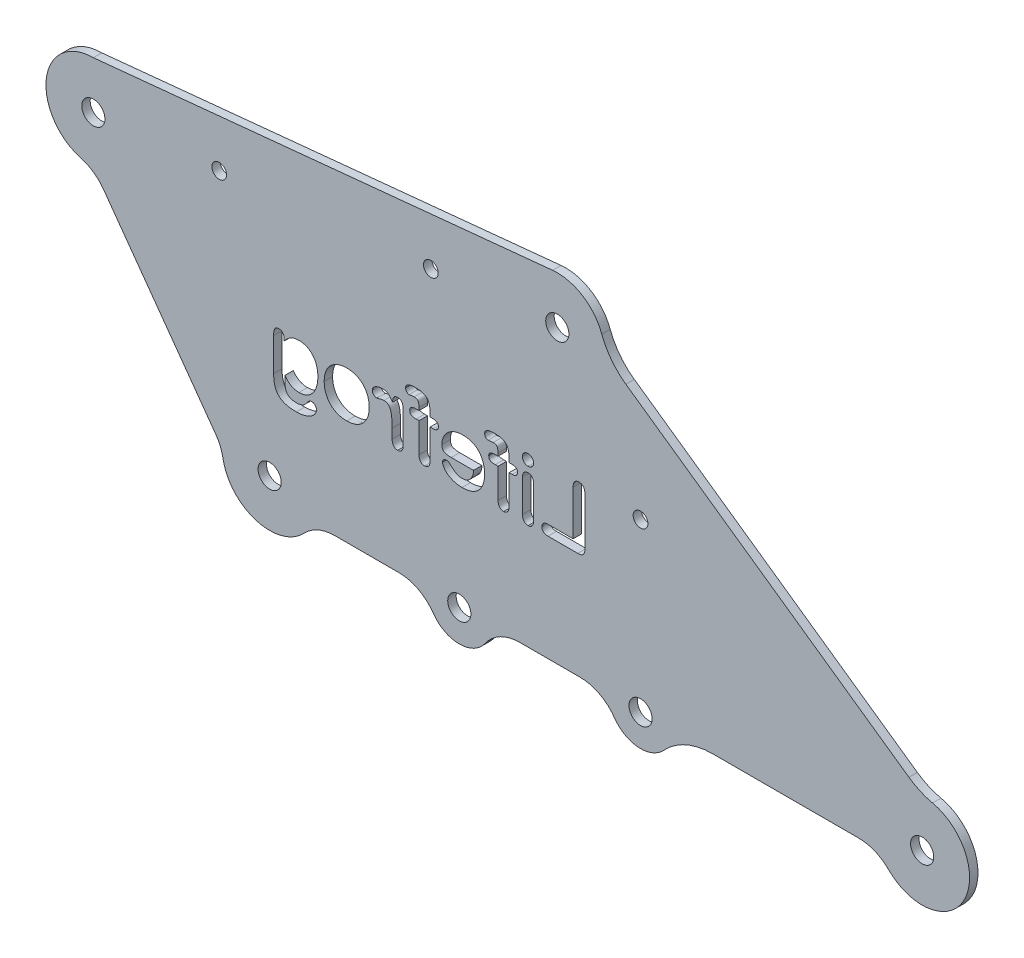
from build123d import *

# Parameters (mm, degrees)
SKETCH2_R           = 2.75
BOSS_EXTRUDE1_DEPTH = 2
SKETCH7_R           = 1.75
CUT_EXTRUDE4_DEPTH  = 3
CUT_EXTRUDE5_DEPTH  = 3
SKETCH9_R           = 4.424451358
SKETCH9_R_2         = 3.80051452
CUT_EXTRUDE6_DEPTH  = 10


with BuildPart() as part:
    # Sketch2 → Boss-Extrude1 (new body)
    with BuildSketch(Plane.XY):
        with BuildLine():
            Line((-146.482261324, -3.415116213), (-119.900209046, -40.345357838))
            ThreePointArc((-119.900209046, -40.345357838), (-118.800607084, -42.305283789), (-118.166440512, -44.46126778))
            ThreePointArc((-118.166440512, -44.46126778), (-110.313224995, -53.296457195), (-98.896144571, -50.233151699))
            ThreePointArc((-98.896144571, -50.233151699), (-95.581387, -47.909162096), (-91.616909182, -47.089734824))
            Line((-91.616909182, -47.089734824), (-76.446691, -47.089734824))
            ThreePointArc((-76.446691, -47.089734824), (-71.817590501, -48.22568222), (-68.240172934, -51.37544911))
            ThreePointArc((-68.240172934, -51.37544911), (-62.085284384, -54.589734824), (-55.930395834, -51.37544911))
            ThreePointArc((-55.930395834, -51.37544911), (-52.352978266, -48.22568222), (-47.723877768, -47.089734824))
            Line((-47.723877768, -47.089734824), (-33.446691, -47.089734824))
            ThreePointArc((-33.446691, -47.089734824), (-28.817590501, -48.22568222), (-25.240172934, -51.37544911))
            ThreePointArc((-25.240172934, -51.37544911), (-19.593639667, -54.572486651), (-13.566591065, -52.168516573))
            ThreePointArc((-13.566591065, -52.168516573), (-8.311100334, -48.415273127), (-1.990501675, -47.089734824))
            Line((-1.990501675, -47.089734824), (32.686636747, -47.089734824))
            ThreePointArc((32.686636747, -47.089734824), (36.521461692, -47.854253372), (39.769927676, -50.030911295))
            ThreePointArc((39.769927676, -50.030911295), (57.590414229, -47.521571248), (50.200722675, -31.112458317))
            ThreePointArc((50.200722675, -31.112458317), (47.278407153, -30.14859154), (44.599620096, -28.63430389))
            Line((44.599620096, -28.63430389), (-22.564700668, 18.554547573))
            ThreePointArc((-22.564700668, 18.554547573), (-25.986792869, 21.830620173), (-28.278442139, 25.976908916))
            ThreePointArc((-28.278442139, 25.976908916), (-32.864492812, 31.616465892), (-39.941717654, 33.27458296))
            Line((-39.941717654, 33.27458296), (-148.918739614, 22.469864413))
            ThreePointArc((-148.918739614, 22.469864413), (-160.065949313, 12.737169894), (-151.925623591, 0.379147243))
            ThreePointArc((-151.925623591, 0.379147243), (-148.880072017, -1.053350399), (-146.482261324, -3.415116213))
        make_face()
        with Locations((47.738629971, -42.089734824)):
            Circle(SKETCH2_R, mode=Mode.SUBTRACT)
        with Locations((-19.085284384, -47.089734824)):
            Circle(SKETCH2_R, mode=Mode.SUBTRACT)
        with Locations((-62.085284384, -47.089734824)):
            Circle(SKETCH2_R, mode=Mode.SUBTRACT)
        with Locations((-107.085284384, -42.519495684)):
            Circle(SKETCH2_R, mode=Mode.SUBTRACT)
        with Locations((-148.918739614, 11.219864413)):
            Circle(SKETCH2_R, mode=Mode.SUBTRACT)
        with Locations((-38.831758764, 22.07947281)):
            Circle(SKETCH2_R, mode=Mode.SUBTRACT)
    extrude(amount=BOSS_EXTRUDE1_DEPTH)

    # Sketch7 → Cut-Extrude4 (cut, through all)
    with BuildSketch(Plane.XY.offset(2)):
        with Locations((-119.063647537, 14.164941171)):
            Circle(SKETCH7_R)
        with Locations((-68.831758764, 19.120101507)):
            Circle(SKETCH7_R)
        with Locations((-19.085284384, -7.519495684)):
            Circle(SKETCH7_R)
    extrude(amount=-CUT_EXTRUDE4_DEPTH, mode=Mode.SUBTRACT)

    # Sketch8 → Cut-Extrude5 (cut, through all)
    with BuildSketch(Plane(origin=(0, 0, 0), x_dir=(-1, 0, 0), z_dir=(0, 0, -1))):
        with BuildLine():
            Line((35.086320726, -8.88917677), (35.086320726, -19.477067395))
            Line((35.086320726, -19.477067395), (41.039445726, -19.477067395))
            add(Edge.make_bspline(
                [(41.039445726, -19.477067395), (41.151207657, -19.479993195), (41.364330782, -19.485572515), (41.662298188, -19.554542719), (41.923339942, -19.661257744), (42.134401002, -19.819951832), (42.304522289, -20.005566477), (42.428077526, -20.217869304), (42.500347045, -20.454899643), (42.50877144, -20.620129964), (42.513078539, -20.704606457)],
                knots=[0, 0, 0, 0, 0.000334613, 0.000638087, 0.000912369, 0.001174294, 0.001423196, 0.001663395, 0.001905285, 0.002158326, 0.002158326, 0.002158326, 0.002158326], degree=3))
            add(Edge.make_bspline(
                [(42.513078539, -20.704606457), (42.508946769, -20.791061883), (42.500954328, -20.958300126), (42.427991131, -21.197153566), (42.305901504, -21.407864411), (42.137936653, -21.589554136), (41.927138947, -21.739731647), (41.667288952, -21.839448431), (41.367976859, -21.905877279), (41.153144472, -21.911559901), (41.039445726, -21.914567395)],
                knots=[0, 0, 0, 0, 0.000258876, 0.000500766, 0.000740964, 0.000983563, 0.001237974, 0.001509993, 0.00181283, 0.002153292, 0.002153292, 0.002153292, 0.002153292], degree=3))
            Line((41.039445726, -21.914567395), (33.996476976, -21.914567395))
            add(Edge.make_bspline(
                [(33.996476976, -21.914567395), (33.853353838, -21.910822677), (33.586803908, -21.903848583), (33.219164265, -21.820051925), (32.910084712, -21.691568649), (32.663815683, -21.496286799), (32.482305295, -21.2361672), (32.358100514, -20.915092293), (32.287886266, -20.530846545), (32.278723904, -20.25471837), (32.273820726, -20.106950207)],
                knots=[0, 0, 0, 0, 0.000428546, 0.000798117, 0.001124734, 0.001424881, 0.001727306, 0.002065149, 0.00245011, 0.002893278, 0.002893278, 0.002893278, 0.002893278], degree=3))
            Line((32.273820726, -20.106950207), (32.273820726, -8.88917677))
            add(Edge.make_bspline(
                [(32.273820726, -8.88917677), (32.277444522, -8.749162056), (32.284268854, -8.485486372), (32.356957437, -8.118037422), (32.476634418, -7.804802622), (32.645141816, -7.546892469), (32.856855173, -7.348035389), (33.099081612, -7.202614303), (33.373976884, -7.118889739), (33.566226734, -7.107793002), (33.665422289, -7.102067395)],
                knots=[0, 0, 0, 0, 0.0004196, 0.000790191, 0.001117701, 0.00141997, 0.001705972, 0.001981814, 0.00226075, 0.002558095, 0.002558095, 0.002558095, 0.002558095], degree=3))
            add(Edge.make_bspline(
                [(33.665422289, -7.102067395), (33.766728298, -7.106162598), (33.963485083, -7.114116312), (34.241681246, -7.204196573), (34.491196095, -7.34317393), (34.705487503, -7.541754535), (34.882515406, -7.795771782), (35.002902616, -8.111096688), (35.076257378, -8.481501141), (35.082815622, -8.747181708), (35.086320726, -8.88917677)],
                knots=[0, 0, 0, 0, 0.000302908, 0.000588308, 0.000867752, 0.001153903, 0.001457037, 0.001788351, 0.002158942, 0.002584392, 0.002584392, 0.002584392, 0.002584392], degree=3))
        make_face()
        with BuildLine():
            Line((47.086320726, -12.74464552), (47.086320726, -20.476090832))
            add(Edge.make_bspline(
                [(47.086320726, -20.476090832), (47.082420593, -20.602435528), (47.075064066, -20.84074997), (47.005182236, -21.174236118), (46.88809835, -21.460321774), (46.722706311, -21.694972614), (46.519526295, -21.876468441), (46.28964053, -22.009165841), (46.031653529, -22.087195916), (45.85149376, -22.097028675), (45.759172289, -22.102067395)],
                knots=[0, 0, 0, 0, 0.000378656, 0.00071423, 0.001016215, 0.001299911, 0.001567541, 0.00182736, 0.002090575, 0.002367225, 0.002367225, 0.002367225, 0.002367225], degree=3))
            add(Edge.make_bspline(
                [(45.759172289, -22.102067395), (45.666704772, -22.097531408), (45.487838174, -22.08875712), (45.23365211, -22.004912745), (45.006451484, -21.871389965), (44.811013414, -21.682373157), (44.650959039, -21.445866625), (44.541087672, -21.160395096), (44.473171135, -20.832780478), (44.465421067, -20.599508451), (44.461320726, -20.476090832)],
                knots=[0, 0, 0, 0, 0.00027665, 0.000535144, 0.000793904, 0.001061213, 0.001343984, 0.001643744, 0.001972979, 0.002342863, 0.002342863, 0.002342863, 0.002342863], degree=3))
            Line((44.461320726, -20.476090832), (44.461320726, -12.823747082))
            add(Edge.make_bspline(
                [(44.461320726, -12.823747082), (44.4655151, -12.699382119), (44.473445887, -12.464230884), (44.539697696, -12.136087305), (44.650415089, -11.854229206), (44.811202223, -11.625466775), (45.007817757, -11.44586487), (45.234070933, -11.317596829), (45.488859368, -11.241954113), (45.666855774, -11.232151465), (45.759172289, -11.227067395)],
                knots=[0, 0, 0, 0, 0.000372808, 0.000704911, 0.000999239, 0.00127477, 0.001536087, 0.001791911, 0.002048673, 0.002325323, 0.002325323, 0.002325323, 0.002325323], degree=3))
            add(Edge.make_bspline(
                [(45.759172289, -11.227067395), (45.851434596, -11.232364163), (46.031201162, -11.242684541), (46.289294531, -11.316791228), (46.519597684, -11.446472242), (46.719799732, -11.624386887), (46.886864263, -11.846010703), (47.003355814, -12.112795725), (47.074726656, -12.416719887), (47.082335115, -12.631916842), (47.086320726, -12.74464552)],
                knots=[0, 0, 0, 0, 0.00027665, 0.000539033, 0.000797411, 0.001063093, 0.001337313, 0.001623179, 0.001930167, 0.002267896, 0.002267896, 0.002267896, 0.002267896], degree=3))
        make_face()
        with BuildLine():
            add(Edge.make_bspline(
                [(45.788469164, -9.914567395), (45.700155278, -9.911112501), (45.527837589, -9.904371326), (45.279123369, -9.837014704), (45.05142568, -9.726888524), (44.844494731, -9.578448802), (44.672494362, -9.386651845), (44.546452039, -9.154497095), (44.472722475, -8.885778489), (44.46522284, -8.695310105), (44.461320726, -8.59620802)],
                knots=[0, 0, 0, 0, 0.000264468, 0.000516029, 0.000766308, 0.001020043, 0.001275262, 0.001532224, 0.00180588, 0.002102705, 0.002102705, 0.002102705, 0.002102705], degree=3))
            add(Edge.make_bspline(
                [(44.461320726, -8.59620802), (44.466503012, -8.504891338), (44.476546269, -8.327919822), (44.551669892, -8.073896193), (44.680826892, -7.848246813), (44.854448523, -7.652100465), (45.060826482, -7.494003153), (45.286053439, -7.371969471), (45.53257688, -7.303278473), (45.702130039, -7.29419357), (45.788469164, -7.289567395)],
                knots=[0, 0, 0, 0, 0.000273734, 0.000530495, 0.000786319, 0.001047867, 0.001310985, 0.001562597, 0.001812103, 0.002070978, 0.002070978, 0.002070978, 0.002070978], degree=3))
            add(Edge.make_bspline(
                [(45.788469164, -7.289567395), (45.871883282, -7.293289281), (46.035245133, -7.300578386), (46.272968232, -7.365176401), (46.494233713, -7.471719022), (46.696092474, -7.61868617), (46.874547315, -7.801949122), (46.996351464, -8.035133325), (47.076989401, -8.302838261), (47.083100242, -8.494958443), (47.086320726, -8.59620802)],
                knots=[0, 0, 0, 0, 0.000249866, 0.000489349, 0.000733078, 0.000982721, 0.001235592, 0.001492554, 0.001764195, 0.002066861, 0.002066861, 0.002066861, 0.002066861], degree=3))
            add(Edge.make_bspline(
                [(47.086320726, -8.59620802), (47.082548229, -8.694407685), (47.075299369, -8.883098506), (46.999769728, -9.148438196), (46.878868744, -9.381879948), (46.705206821, -9.571319036), (46.504492812, -9.722899361), (46.282136483, -9.833786351), (46.041845864, -9.904963009), (45.873933033, -9.911327839), (45.788469164, -9.914567395)],
                knots=[0, 0, 0, 0, 0.000293905, 0.000564738, 0.000820311, 0.00107553, 0.001328656, 0.001571042, 0.001817728, 0.002073434, 0.002073434, 0.002073434, 0.002073434], degree=3))
        make_face()
        with BuildLine():
            Line((49.632219164, -11.414567395), (50.273820726, -11.414567395))
            Line((50.273820726, -11.414567395), (50.273820726, -10.591325207))
            add(Edge.make_bspline(
                [(50.273820726, -10.591325207), (50.277514056, -10.388045332), (50.284509589, -10.00301306), (50.342549558, -9.457909943), (50.436641901, -8.978381027), (50.569332837, -8.557808501), (50.755633772, -8.195572563), (50.996610195, -7.887535194), (51.293777818, -7.633608774), (51.648730133, -7.431434885), (52.067068931, -7.280410479), (52.552532894, -7.174729198), (53.108091552, -7.111487828), (53.502156344, -7.105323868), (53.710344164, -7.102067395)],
                knots=[0, 0, 0, 0, 0.00060972, 0.00115487, 0.001642098, 0.002073827, 0.00247349, 0.00285738, 0.003239656, 0.003638653, 0.004076188, 0.004568733, 0.005126183, 0.005750543, 0.005750543, 0.005750543, 0.005750543], degree=3))
            add(Edge.make_bspline(
                [(53.710344164, -7.102067395), (53.895146779, -7.104261268), (54.241413904, -7.108371958), (54.723647309, -7.168286024), (55.135762658, -7.255167266), (55.473032061, -7.391161667), (55.744889456, -7.558653085), (55.937764712, -7.776533401), (56.05427242, -8.037027657), (56.067659952, -8.223910447), (56.074601976, -8.320817395)],
                knots=[0, 0, 0, 0, 0.00055399, 0.001038018, 0.001455897, 0.001813331, 0.002124554, 0.002404841, 0.002673751, 0.002963375, 0.002963375, 0.002963375, 0.002963375], degree=3))
            add(Edge.make_bspline(
                [(56.074601976, -8.320817395), (56.07205453, -8.384563693), (56.067042815, -8.509974928), (56.019565864, -8.690669099), (55.937272087, -8.855101057), (55.831089458, -9.002344218), (55.703605103, -9.125761707), (55.560931421, -9.215318606), (55.405925119, -9.272564588), (55.297752865, -9.278650351), (55.242570726, -9.281754895)],
                knots=[0, 0, 0, 0, 0.000190992, 0.000375748, 0.00055525, 0.000739844, 0.00091805, 0.001083881, 0.001242328, 0.00140733, 0.00140733, 0.00140733, 0.00140733], degree=3))
            add(Edge.make_bspline(
                [(55.242570726, -9.281754895), (55.211291096, -9.281243662), (55.139763808, -9.280074624), (55.017892004, -9.265550853), (54.867145158, -9.249871502), (54.639618335, -9.213428957), (54.363834674, -9.175272517), (54.14601204, -9.167906783), (54.047258226, -9.164567395)],
                knots=[0, 0, 0, 0, 9.3796e-05, 0.000214483, 0.000367838, 0.000548483, 0.000905689, 0.00120195, 0.00120195, 0.00120195, 0.00120195], degree=3))
            add(Edge.make_bspline(
                [(54.047258226, -9.164567395), (53.935335203, -9.168513751), (53.730509601, -9.175735811), (53.453388449, -9.253609551), (53.236438618, -9.387787922), (53.093840565, -9.587280743), (53.00705741, -9.82836939), (52.94477266, -10.108223991), (52.902635068, -10.432859402), (52.900145328, -10.66441903), (52.898820726, -10.78761427)],
                knots=[0, 0, 0, 0, 0.000335024, 0.000613112, 0.000854452, 0.001084726, 0.001333353, 0.001619039, 0.001943904, 0.00231323, 0.00231323, 0.00231323, 0.00231323], degree=3))
            Line((52.898820726, -10.78761427), (52.898820726, -11.414567395))
            Line((52.898820726, -11.414567395), (53.563859789, -11.414567395))
            add(Edge.make_bspline(
                [(53.563859789, -11.414567395), (53.684179087, -11.416649074), (53.910242779, -11.420560268), (54.225792592, -11.467875581), (54.49621768, -11.540251074), (54.718209635, -11.648680399), (54.893566863, -11.789413733), (55.016660753, -11.965226471), (55.094330745, -12.172143548), (55.10125483, -12.32106946), (55.104875414, -12.398942395)],
                knots=[0, 0, 0, 0, 0.000360649, 0.000677611, 0.000954881, 0.001197267, 0.001413707, 0.001621798, 0.001834054, 0.002066683, 0.002066683, 0.002066683, 0.002066683], degree=3))
            add(Edge.make_bspline(
                [(55.104875414, -12.398942395), (55.100784732, -12.506003658), (55.0933337, -12.701011923), (55.017531846, -12.965095468), (54.888175636, -13.171513058), (54.692271136, -13.302589493), (54.461307669, -13.37783369), (54.196374468, -13.437731598), (53.892808985, -13.470942071), (53.677213775, -13.474956644), (53.563859789, -13.477067395)],
                knots=[0, 0, 0, 0, 0.000320423, 0.000583638, 0.000816027, 0.001034677, 0.001274715, 0.00154196, 0.001848669, 0.002188714, 0.002188714, 0.002188714, 0.002188714], degree=3))
            Line((53.563859789, -13.477067395), (52.898820726, -13.477067395))
            Line((52.898820726, -13.477067395), (52.898820726, -20.49073927))
            add(Edge.make_bspline(
                [(52.898820726, -20.49073927), (52.894890647, -20.614179922), (52.887425469, -20.848655192), (52.816934516, -21.176561155), (52.703366177, -21.461585314), (52.538062875, -21.695052259), (52.335369862, -21.875428653), (52.106713482, -22.010618694), (51.846897908, -22.086940159), (51.664920121, -22.096942211), (51.571672289, -22.102067395)],
                knots=[0, 0, 0, 0, 0.000369884, 0.000702594, 0.001000746, 0.001284442, 0.001552072, 0.001809351, 0.002075373, 0.002354939, 0.002354939, 0.002354939, 0.002354939], degree=3))
            add(Edge.make_bspline(
                [(51.571672289, -22.102067395), (51.482224977, -22.09710813), (51.307699782, -22.087431855), (51.057160741, -22.007724342), (50.831657988, -21.876461922), (50.631448396, -21.694722042), (50.469647741, -21.460721404), (50.355528177, -21.176665365), (50.285268804, -20.8486244), (50.277769023, -20.614169302), (50.273820726, -20.49073927)],
                knots=[0, 0, 0, 0, 0.000267902, 0.000522718, 0.000779997, 0.001045453, 0.001327465, 0.001625617, 0.001958327, 0.002328211, 0.002328211, 0.002328211, 0.002328211], degree=3))
            Line((50.273820726, -20.49073927), (50.273820726, -13.477067395))
            Line((50.273820726, -13.477067395), (49.532609789, -13.477067395))
            add(Edge.make_bspline(
                [(49.532609789, -13.477067395), (49.437497333, -13.474545828), (49.257144996, -13.469764431), (49.004612129, -13.411306638), (48.782055088, -13.326305771), (48.598641031, -13.197615767), (48.451306666, -13.041843238), (48.352045043, -12.858126156), (48.285842232, -12.656347119), (48.279207657, -12.513757181), (48.275773851, -12.43995802)],
                knots=[0, 0, 0, 0, 0.000284723, 0.000539892, 0.000773827, 0.000994878, 0.001206343, 0.00141094, 0.001616645, 0.001837326, 0.001837326, 0.001837326, 0.001837326], degree=3))
            add(Edge.make_bspline(
                [(48.275773851, -12.43995802), (48.278931014, -12.359364997), (48.28493967, -12.205981751), (48.351465421, -11.99217143), (48.459813646, -11.809230275), (48.613188222, -11.659732473), (48.810357544, -11.547566221), (49.047458479, -11.470404208), (49.325403123, -11.419710271), (49.525517403, -11.416355939), (49.632219164, -11.414567395)],
                knots=[0, 0, 0, 0, 0.000241108, 0.000458873, 0.000663867, 0.000873109, 0.001093694, 0.001338283, 0.001618141, 0.001937813, 0.001937813, 0.001937813, 0.001937813], degree=3))
        make_face()
        with BuildLine():
            Line((63.993547289, -17.227067395), (58.711320726, -17.227067395))
            add(Edge.make_bspline(
                [(58.711320726, -17.227067395), (58.716485938, -17.373895282), (58.726607174, -17.661604604), (58.802714884, -18.07799563), (58.915860462, -18.469071713), (59.073647335, -18.829619398), (59.270554735, -19.153364248), (59.492765404, -19.442705533), (59.750507136, -19.684973297), (60.03645821, -19.88267243), (60.345770403, -20.033615445), (60.670482904, -20.148105778), (61.01253608, -20.212156224), (61.245255038, -20.222066531), (61.362687914, -20.227067395)],
                knots=[0, 0, 0, 0, 0.000440243, 0.000862657, 0.001265902, 0.001659452, 0.002039296, 0.002400313, 0.002750567, 0.003095948, 0.003439221, 0.003780175, 0.004126076, 0.004478419, 0.004478419, 0.004478419, 0.004478419], degree=3))
            add(Edge.make_bspline(
                [(61.362687914, -20.227067395), (61.517315025, -20.221290078), (61.81522082, -20.210159454), (62.248320892, -20.128402077), (62.65037596, -19.976572402), (63.029981243, -19.770423211), (63.382588562, -19.521193305), (63.667016112, -19.296133613), (63.89432751, -19.094787244), (64.085795058, -18.918875484), (64.304668367, -18.722900775), (64.455732274, -18.581855292), (64.535539476, -18.507340832)],
                knots=[0, 0, 0, 0, 0.000463817, 0.000893593, 0.001315356, 0.001747919, 0.002185944, 0.00260917, 0.00283544, 0.003096758, 0.003389213, 0.003716762, 0.003716762, 0.003716762, 0.003716762], degree=3))
            add(Edge.make_bspline(
                [(64.535539476, -18.507340832), (64.572653698, -18.48027204), (64.649909263, -18.423926662), (64.791469612, -18.369543996), (64.954050743, -18.338198915), (65.069560502, -18.333846809), (65.130266039, -18.331559582)],
                knots=[0, 0, 0, 0, 0.000137321, 0.000285842, 0.000450166, 0.000632184, 0.000632184, 0.000632184, 0.000632184], degree=3))
            add(Edge.make_bspline(
                [(65.130266039, -18.331559582), (65.197009882, -18.333900139), (65.324294385, -18.33836372), (65.504066974, -18.385198991), (65.666679189, -18.453914722), (65.804779268, -18.559309462), (65.921073021, -18.686697731), (66.001439392, -18.843467551), (66.053282091, -19.021621344), (66.057023071, -19.149522649), (66.058976976, -19.216325207)],
                knots=[0, 0, 0, 0, 0.000199757, 0.000380948, 0.000554072, 0.000725753, 0.000898008, 0.001067069, 0.001249769, 0.001449526, 0.001449526, 0.001449526, 0.001449526], degree=3))
            add(Edge.make_bspline(
                [(66.058976976, -19.216325207), (66.055140543, -19.281058441), (66.047007822, -19.418284177), (65.990684139, -19.630580971), (65.89753, -19.856403047), (65.771680317, -20.095129398), (65.612344825, -20.341196211), (65.409653802, -20.580823639), (65.174931597, -20.819411181), (64.902221637, -21.049528185), (64.595344086, -21.269822809), (64.249335099, -21.470546591), (63.864239991, -21.646257285), (63.446257949, -21.809324299), (62.992864569, -21.941257019), (62.504327356, -22.0333954), (61.984342492, -22.094193404), (61.625563625, -22.099400308), (61.441789476, -22.102067395)],
                knots=[0, 0, 0, 0, 0.000194157, 0.000411586, 0.000654768, 0.000926029, 0.001220182, 0.001532273, 0.001865807, 0.002223301, 0.002601333, 0.002997794, 0.003421152, 0.003870016, 0.004342868, 0.004835273, 0.005360039, 0.005911101, 0.005911101, 0.005911101, 0.005911101], degree=3))
            add(Edge.make_bspline(
                [(61.441789476, -22.102067395), (61.231648736, -22.097519737), (60.821964685, -22.088653761), (60.226784289, -22.021353682), (59.669210967, -21.908362258), (59.150569744, -21.745772772), (58.667513306, -21.542562166), (58.224053508, -21.288395048), (57.820679107, -20.987522623), (57.455460166, -20.64373407), (57.134442572, -20.257975864), (56.850340149, -19.841633038), (56.616330833, -19.388813691), (56.421842234, -18.905299727), (56.270116103, -18.389217889), (56.162139879, -17.840151988), (56.09676424, -17.258936562), (56.089857706, -16.86005426), (56.086320726, -16.655778332)],
                knots=[0, 0, 0, 0, 0.000630319, 0.00122885, 0.001794227, 0.002334443, 0.002856848, 0.003363404, 0.003863798, 0.004363265, 0.004864412, 0.005366578, 0.005872397, 0.006390314, 0.006927974, 0.007483573, 0.00806722, 0.008679868, 0.008679868, 0.008679868, 0.008679868], degree=3))
            add(Edge.make_bspline(
                [(56.086320726, -16.655778332), (56.089863596, -16.462226663), (56.096844531, -16.080848933), (56.163955879, -15.519624607), (56.268451373, -14.979723953), (56.413728423, -14.462108781), (56.604168314, -13.975533109), (56.829293377, -13.519340339), (57.098097208, -13.102077052), (57.402287332, -12.718106315), (57.750981266, -12.376213514), (58.140980683, -12.074737303), (58.573216423, -11.817183613), (59.045085371, -11.603132446), (59.551427203, -11.433045112), (60.089833345, -11.315293392), (60.656383848, -11.238702527), (61.044069017, -11.231007425), (61.242570726, -11.227067395)],
                knots=[0, 0, 0, 0, 0.000580441, 0.001143711, 0.001692994, 0.002229023, 0.002754034, 0.003258459, 0.00375257, 0.004240308, 0.00472508, 0.005213803, 0.005715738, 0.006230972, 0.006765533, 0.007314957, 0.007882205, 0.008477394, 0.008477394, 0.008477394, 0.008477394], degree=3))
            add(Edge.make_bspline(
                [(61.242570726, -11.227067395), (61.372538981, -11.22810589), (61.627045231, -11.23013949), (62.001408011, -11.265268194), (62.362503375, -11.313850777), (62.710727077, -11.382379075), (63.04253843, -11.478141357), (63.361054388, -11.589179566), (63.666118712, -11.720379466), (63.955121946, -11.874248291), (64.230989577, -12.038773815), (64.485024674, -12.223475089), (64.726773861, -12.411434191), (64.947774364, -12.616494045), (65.15303199, -12.831425773), (65.33677691, -13.06140635), (65.506460871, -13.299708893), (65.701149201, -13.632045496), (65.90499798, -14.058699678), (66.086744263, -14.582630241), (66.196585792, -15.115069491), (66.210329972, -15.472667779), (66.217180101, -15.65089552)],
                knots=[0, 0, 0, 0, 0.000389748, 0.000763211, 0.001126988, 0.00148264, 0.001826713, 0.002162134, 0.002494121, 0.002821735, 0.003143801, 0.003456784, 0.003763339, 0.004061909, 0.004360335, 0.004654079, 0.004944251, 0.005237176, 0.005808517, 0.006359774, 0.006897561, 0.007431922, 0.007431922, 0.007431922, 0.007431922], degree=3))
            add(Edge.make_bspline(
                [(66.217180101, -15.65089552), (66.215610952, -15.730068621), (66.212617901, -15.881086234), (66.186937014, -16.097314554), (66.140772023, -16.291180146), (66.075053252, -16.464024902), (65.995488051, -16.617172785), (65.89278487, -16.74579461), (65.773975455, -16.854326494), (65.582181996, -16.968584464), (65.300769745, -17.07492862), (64.916543956, -17.164445981), (64.474589043, -17.219117531), (64.159728488, -17.224321026), (63.993547289, -17.227067395)],
                knots=[0, 0, 0, 0, 0.000237467, 0.000452954, 0.000651914, 0.000833649, 0.001006674, 0.001167274, 0.001324933, 0.00148673, 0.001833821, 0.00222251, 0.002668381, 0.003166738, 0.003166738, 0.003166738, 0.003166738], degree=3))
        make_face()
        with BuildLine():
            Line((58.711320726, -15.727067395), (63.606828539, -15.727067395))
            add(Edge.make_bspline(
                [(63.606828539, -15.727067395), (63.597892017, -15.620388862), (63.580506578, -15.412852503), (63.525243597, -15.113999216), (63.460289426, -14.835108466), (63.374142884, -14.577543089), (63.272543011, -14.341165405), (63.154505162, -14.123236857), (63.017386306, -13.928050969), (62.863841728, -13.753386376), (62.694974951, -13.600302554), (62.514511391, -13.465060191), (62.318539721, -13.352382039), (62.109343802, -13.262997606), (61.88971522, -13.187447347), (61.65522259, -13.140138129), (61.409640164, -13.105158478), (61.240753138, -13.103110926), (61.154680101, -13.102067395)],
                knots=[0, 0, 0, 0, 0.000320958, 0.000624403, 0.000910764, 0.001179435, 0.001437945, 0.001681814, 0.001921584, 0.002151988, 0.00237803, 0.002604205, 0.002827324, 0.003054294, 0.003285906, 0.00352265, 0.003770844, 0.004028807, 0.004028807, 0.004028807, 0.004028807], degree=3))
            add(Edge.make_bspline(
                [(61.154680101, -13.102067395), (61.072577515, -13.10475237), (60.911762666, -13.110011447), (60.674960792, -13.138599654), (60.450175128, -13.191199261), (60.236485897, -13.265652746), (60.033877273, -13.359118289), (59.842432731, -13.474146939), (59.662756958, -13.609700616), (59.495375907, -13.766189336), (59.339368932, -13.941320054), (59.201880517, -14.138573533), (59.081832188, -14.355594311), (58.972348183, -14.589561112), (58.881951346, -14.845787112), (58.809840485, -15.122470817), (58.750931011, -15.417941176), (58.724734593, -15.622383021), (58.711320726, -15.727067395)],
                knots=[0, 0, 0, 0, 0.000246373, 0.000482572, 0.000714239, 0.000937531, 0.00116036, 0.001382438, 0.001606266, 0.001834293, 0.002068833, 0.002308603, 0.002553893, 0.002812121, 0.003082701, 0.003367665, 0.003669309, 0.003985851, 0.003985851, 0.003985851, 0.003985851], degree=3))
        make_face(mode=Mode.SUBTRACT)
        with BuildLine():
            Line((68.382219164, -11.414567395), (69.023820726, -11.414567395))
            Line((69.023820726, -11.414567395), (69.023820726, -10.591325207))
            add(Edge.make_bspline(
                [(69.023820726, -10.591325207), (69.027514056, -10.388045332), (69.034509589, -10.00301306), (69.092549558, -9.457909943), (69.186641901, -8.978381027), (69.319332837, -8.557808501), (69.505633772, -8.195572563), (69.746610195, -7.887535194), (70.043777818, -7.633608774), (70.398730133, -7.431434885), (70.817068931, -7.280410479), (71.302532894, -7.174729198), (71.858091552, -7.111487828), (72.252156344, -7.105323868), (72.460344164, -7.102067395)],
                knots=[0, 0, 0, 0, 0.00060972, 0.00115487, 0.001642098, 0.002073827, 0.00247349, 0.00285738, 0.003239656, 0.003638653, 0.004076188, 0.004568733, 0.005126183, 0.005750543, 0.005750543, 0.005750543, 0.005750543], degree=3))
            add(Edge.make_bspline(
                [(72.460344164, -7.102067395), (72.645146779, -7.104261268), (72.991413904, -7.108371958), (73.473647309, -7.168286024), (73.885762658, -7.255167266), (74.223032061, -7.391161667), (74.494889456, -7.558653085), (74.687764712, -7.776533401), (74.80427242, -8.037027657), (74.817659952, -8.223910447), (74.824601976, -8.320817395)],
                knots=[0, 0, 0, 0, 0.00055399, 0.001038018, 0.001455897, 0.001813331, 0.002124554, 0.002404841, 0.002673751, 0.002963375, 0.002963375, 0.002963375, 0.002963375], degree=3))
            add(Edge.make_bspline(
                [(74.824601976, -8.320817395), (74.82205453, -8.384563693), (74.817042815, -8.509974928), (74.769565864, -8.690669099), (74.687272087, -8.855101057), (74.581089458, -9.002344218), (74.453605103, -9.125761707), (74.310931421, -9.215318606), (74.155925119, -9.272564588), (74.047752865, -9.278650351), (73.992570726, -9.281754895)],
                knots=[0, 0, 0, 0, 0.000190992, 0.000375748, 0.00055525, 0.000739844, 0.00091805, 0.001083881, 0.001242328, 0.00140733, 0.00140733, 0.00140733, 0.00140733], degree=3))
            add(Edge.make_bspline(
                [(73.992570726, -9.281754895), (73.961291096, -9.281243662), (73.889763808, -9.280074624), (73.767892004, -9.265550853), (73.617145158, -9.249871502), (73.389618335, -9.213428957), (73.113834674, -9.175272517), (72.89601204, -9.167906783), (72.797258226, -9.164567395)],
                knots=[0, 0, 0, 0, 9.3796e-05, 0.000214483, 0.000367838, 0.000548483, 0.000905689, 0.00120195, 0.00120195, 0.00120195, 0.00120195], degree=3))
            add(Edge.make_bspline(
                [(72.797258226, -9.164567395), (72.685335203, -9.168513751), (72.480509601, -9.175735811), (72.203388449, -9.253609551), (71.986438618, -9.387787922), (71.843840565, -9.587280743), (71.75705741, -9.82836939), (71.69477266, -10.108223991), (71.652635068, -10.432859402), (71.650145328, -10.66441903), (71.648820726, -10.78761427)],
                knots=[0, 0, 0, 0, 0.000335024, 0.000613112, 0.000854452, 0.001084726, 0.001333353, 0.001619039, 0.001943904, 0.00231323, 0.00231323, 0.00231323, 0.00231323], degree=3))
            Line((71.648820726, -10.78761427), (71.648820726, -11.414567395))
            Line((71.648820726, -11.414567395), (72.313859789, -11.414567395))
            add(Edge.make_bspline(
                [(72.313859789, -11.414567395), (72.434179087, -11.416649074), (72.660242779, -11.420560268), (72.975792592, -11.467875581), (73.24621768, -11.540251074), (73.468209635, -11.648680399), (73.643566863, -11.789413733), (73.766660753, -11.965226471), (73.844330745, -12.172143548), (73.85125483, -12.32106946), (73.854875414, -12.398942395)],
                knots=[0, 0, 0, 0, 0.000360649, 0.000677611, 0.000954881, 0.001197267, 0.001413707, 0.001621798, 0.001834054, 0.002066683, 0.002066683, 0.002066683, 0.002066683], degree=3))
            add(Edge.make_bspline(
                [(73.854875414, -12.398942395), (73.850784732, -12.506003658), (73.8433337, -12.701011923), (73.767531846, -12.965095468), (73.638175636, -13.171513058), (73.442271136, -13.302589493), (73.211307669, -13.37783369), (72.946374468, -13.437731598), (72.642808985, -13.470942071), (72.427213775, -13.474956644), (72.313859789, -13.477067395)],
                knots=[0, 0, 0, 0, 0.000320423, 0.000583638, 0.000816027, 0.001034677, 0.001274715, 0.00154196, 0.001848669, 0.002188714, 0.002188714, 0.002188714, 0.002188714], degree=3))
            Line((72.313859789, -13.477067395), (71.648820726, -13.477067395))
            Line((71.648820726, -13.477067395), (71.648820726, -20.49073927))
            add(Edge.make_bspline(
                [(71.648820726, -20.49073927), (71.644890647, -20.614179922), (71.637425469, -20.848655192), (71.566934516, -21.176561155), (71.453366177, -21.461585314), (71.288062875, -21.695052259), (71.085369862, -21.875428653), (70.856713482, -22.010618694), (70.596897908, -22.086940159), (70.414920121, -22.096942211), (70.321672289, -22.102067395)],
                knots=[0, 0, 0, 0, 0.000369884, 0.000702594, 0.001000746, 0.001284442, 0.001552072, 0.001809351, 0.002075373, 0.002354939, 0.002354939, 0.002354939, 0.002354939], degree=3))
            add(Edge.make_bspline(
                [(70.321672289, -22.102067395), (70.232224977, -22.09710813), (70.057699782, -22.087431855), (69.807160741, -22.007724342), (69.581657988, -21.876461922), (69.381448396, -21.694722042), (69.219647741, -21.460721404), (69.105528177, -21.176665365), (69.035268804, -20.8486244), (69.027769023, -20.614169302), (69.023820726, -20.49073927)],
                knots=[0, 0, 0, 0, 0.000267902, 0.000522718, 0.000779997, 0.001045453, 0.001327465, 0.001625617, 0.001958327, 0.002328211, 0.002328211, 0.002328211, 0.002328211], degree=3))
            Line((69.023820726, -20.49073927), (69.023820726, -13.477067395))
            Line((69.023820726, -13.477067395), (68.282609789, -13.477067395))
            add(Edge.make_bspline(
                [(68.282609789, -13.477067395), (68.187497333, -13.474545828), (68.007144996, -13.469764431), (67.754612129, -13.411306638), (67.532055088, -13.326305771), (67.348641031, -13.197615767), (67.201306666, -13.041843238), (67.102045043, -12.858126156), (67.035842232, -12.656347119), (67.029207657, -12.513757181), (67.025773851, -12.43995802)],
                knots=[0, 0, 0, 0, 0.000284723, 0.000539892, 0.000773827, 0.000994878, 0.001206343, 0.00141094, 0.001616645, 0.001837326, 0.001837326, 0.001837326, 0.001837326], degree=3))
            add(Edge.make_bspline(
                [(67.025773851, -12.43995802), (67.028931014, -12.359364997), (67.03493967, -12.205981751), (67.101465421, -11.99217143), (67.209813646, -11.809230275), (67.363188222, -11.659732473), (67.560357544, -11.547566221), (67.797458479, -11.470404208), (68.075403123, -11.419710271), (68.275517403, -11.416355939), (68.382219164, -11.414567395)],
                knots=[0, 0, 0, 0, 0.000241108, 0.000458873, 0.000663867, 0.000873109, 0.001093694, 0.001338283, 0.001618141, 0.001937813, 0.001937813, 0.001937813, 0.001937813], degree=3))
        make_face()
        with BuildLine():
            Line((78.023820726, -18.21730177), (78.023820726, -20.464372082))
            add(Edge.make_bspline(
                [(78.023820726, -20.464372082), (78.019892411, -20.592663462), (78.012477123, -20.83483283), (77.942998305, -21.173173015), (77.826395379, -21.46268977), (77.660008013, -21.697626109), (77.457891862, -21.879946249), (77.226225762, -22.008518529), (76.969273636, -22.08740627), (76.789034454, -22.097099946), (76.696672289, -22.102067395)],
                knots=[0, 0, 0, 0, 0.000384504, 0.000725809, 0.001030497, 0.001314193, 0.001581823, 0.001840201, 0.002103416, 0.002380066, 0.002380066, 0.002380066, 0.002380066], degree=3))
            add(Edge.make_bspline(
                [(76.696672289, -22.102067395), (76.605316881, -22.09710505), (76.427986301, -22.087472609), (76.174585021, -22.009227395), (75.950610673, -21.875274697), (75.750230464, -21.695716107), (75.591715438, -21.458957778), (75.476710712, -21.174115576), (75.410996302, -20.840355995), (75.403041563, -20.602368539), (75.398820726, -20.476090832)],
                knots=[0, 0, 0, 0, 0.000273734, 0.000531346, 0.000786095, 0.001051551, 0.001331899, 0.00163276, 0.001967732, 0.002346388, 0.002346388, 0.002346388, 0.002346388], degree=3))
            Line((75.398820726, -20.476090832), (75.398820726, -13.028825207))
            add(Edge.make_bspline(
                [(75.398820726, -13.028825207), (75.402484719, -12.887967816), (75.409365917, -12.623429237), (75.466438734, -12.253599122), (75.562647251, -11.937580399), (75.705960969, -11.678454634), (75.886700953, -11.470839169), (76.115388002, -11.325648529), (76.384574397, -11.24325969), (76.575973652, -11.232631094), (76.676164476, -11.227067395)],
                knots=[0, 0, 0, 0, 0.000422373, 0.000793242, 0.001119373, 0.001407914, 0.001675543, 0.001936417, 0.002209759, 0.00251002, 0.00251002, 0.00251002, 0.00251002], degree=3))
            add(Edge.make_bspline(
                [(76.676164476, -11.227067395), (76.778250892, -11.23166171), (76.970074096, -11.240294554), (77.23647969, -11.31618665), (77.457457209, -11.448839438), (77.627712083, -11.63900255), (77.758010721, -11.876050227), (77.852605586, -12.159893812), (77.912208923, -12.492418163), (77.927694018, -12.729745798), (77.935930101, -12.855973645)],
                knots=[0, 0, 0, 0, 0.000305826, 0.000574656, 0.000821863, 0.001068601, 0.001330968, 0.001628371, 0.001962214, 0.002341515, 0.002341515, 0.002341515, 0.002341515], degree=3))
            add(Edge.make_bspline(
                [(77.935930101, -12.855973645), (78.015060213, -12.728702257), (78.166410553, -12.485273209), (78.414258837, -12.155879517), (78.661252631, -11.872664951), (78.918064986, -11.635812705), (79.199992654, -11.445181426), (79.525823034, -11.317799074), (79.892305657, -11.240889927), (80.150364302, -11.231818927), (80.285539476, -11.227067395)],
                knots=[0, 0, 0, 0, 0.000449399, 0.000859555, 0.001235207, 0.001575354, 0.001905253, 0.002249625, 0.002617939, 0.003023095, 0.003023095, 0.003023095, 0.003023095], degree=3))
            add(Edge.make_bspline(
                [(80.285539476, -11.227067395), (80.426467245, -11.232489358), (80.70936151, -11.243373249), (81.129162593, -11.320929872), (81.541294315, -11.453132582), (81.873448057, -11.600397905), (82.12154417, -11.742608322), (82.286513298, -11.857020394), (82.423463313, -11.98382965), (82.540429583, -12.115426572), (82.630091374, -12.257833616), (82.691453181, -12.409798496), (82.732078243, -12.569674136), (82.735800435, -12.679941298), (82.737687914, -12.735856457)],
                knots=[0, 0, 0, 0, 0.000422698, 0.000848512, 0.001275654, 0.00171888, 0.001935459, 0.00213299, 0.002319618, 0.002494076, 0.002659908, 0.002821493, 0.002984216, 0.003151619, 0.003151619, 0.003151619, 0.003151619], degree=3))
            add(Edge.make_bspline(
                [(82.737687914, -12.735856457), (82.734447601, -12.813574254), (82.728170407, -12.9641306), (82.658798765, -13.177988977), (82.553564502, -13.372817877), (82.402963372, -13.536083886), (82.232143043, -13.670264449), (82.04869511, -13.768279515), (81.85786951, -13.830801857), (81.727395914, -13.839133704), (81.662492601, -13.843278332)],
                knots=[0, 0, 0, 0, 0.000232352, 0.000450117, 0.000667803, 0.000891881, 0.00111106, 0.001316827, 0.001513269, 0.001707713, 0.001707713, 0.001707713, 0.001707713], degree=3))
            add(Edge.make_bspline(
                [(81.662492601, -13.843278332), (81.629178627, -13.840040056), (81.542984296, -13.831661558), (81.39025665, -13.792022204), (81.183740219, -13.737267753), (80.939095726, -13.659990651), (80.677274642, -13.576472525), (80.415801332, -13.523477689), (80.172440405, -13.484406004), (80.015169718, -13.479444147), (79.939836351, -13.477067395)],
                knots=[0, 0, 0, 0, 0.000100296, 0.0002595, 0.000471998, 0.000741673, 0.001029021, 0.001295639, 0.001541331, 0.001767221, 0.001767221, 0.001767221, 0.001767221], degree=3))
            add(Edge.make_bspline(
                [(79.939836351, -13.477067395), (79.845889074, -13.48141761), (79.66407233, -13.489836608), (79.402436427, -13.542788927), (79.170931902, -13.646030446), (78.963806071, -13.78176069), (78.785197235, -13.961357491), (78.627437355, -14.175620461), (78.492532222, -14.42885195), (78.379665037, -14.716376161), (78.288170049, -15.037011302), (78.209419115, -15.386257938), (78.144574547, -15.764579045), (78.099652318, -16.17561647), (78.064172897, -16.623081436), (78.042345893, -17.113612554), (78.02739976, -17.649826852), (78.025046467, -18.022954037), (78.023820726, -18.21730177)],
                knots=[0, 0, 0, 0, 0.000281997, 0.00054575, 0.000795032, 0.001037984, 0.001284513, 0.001550535, 0.001833686, 0.002142695, 0.002475508, 0.002833002, 0.003216388, 0.003626303, 0.004073002, 0.00456282, 0.005099153, 0.005682191, 0.005682191, 0.005682191, 0.005682191], degree=3))
        make_face()
        with BuildLine():
            add(Edge.make_bspline(
                [(94.148820726, -16.67042677), (94.144486428, -16.865958198), (94.135962174, -17.250509443), (94.063694953, -17.815248603), (93.947256433, -18.356735194), (93.783210596, -18.872727585), (93.575555832, -19.359535852), (93.326640268, -19.813005753), (93.033540056, -20.230278447), (92.700172687, -20.609939276), (92.32896808, -20.9531364), (91.919659255, -21.251299839), (91.478131715, -21.51184656), (91.000994931, -21.724708392), (90.492501837, -21.896725611), (89.950942693, -22.014013606), (89.380489134, -22.090278252), (88.989896722, -22.098082029), (88.790422289, -22.102067395)],
                knots=[0, 0, 0, 0, 0.000586406, 0.001153284, 0.001704937, 0.002246033, 0.002774978, 0.003290312, 0.003795052, 0.004301608, 0.004803364, 0.005308469, 0.005817966, 0.006338536, 0.006873097, 0.00742538, 0.007998439, 0.008596555, 0.008596555, 0.008596555, 0.008596555], degree=3))
            add(Edge.make_bspline(
                [(88.790422289, -22.102067395), (88.591870928, -22.098480665), (88.203960118, -22.091473252), (87.638922615, -22.010038917), (87.101578123, -21.894122427), (86.597818959, -21.719498742), (86.124926323, -21.501305834), (85.684600318, -21.240748892), (85.277774178, -20.936460383), (84.904876516, -20.593622978), (84.569894039, -20.211571465), (84.277056806, -19.794745386), (84.02509942, -19.345794671), (83.821438064, -18.863747925), (83.658781072, -18.352053245), (83.547410974, -17.811904116), (83.473790099, -17.246665517), (83.465530656, -16.861096277), (83.461320726, -16.664567395)],
                knots=[0, 0, 0, 0, 0.000595188, 0.001162822, 0.001709388, 0.002242116, 0.002758572, 0.003269557, 0.003774051, 0.004279946, 0.004786502, 0.005295324, 0.005805536, 0.006327941, 0.006862567, 0.007413605, 0.007980483, 0.008569816, 0.008569816, 0.008569816, 0.008569816], degree=3))
            add(Edge.make_bspline(
                [(83.461320726, -16.664567395), (83.465514225, -16.466082785), (83.473742721, -16.076615619), (83.547624747, -15.505610155), (83.658102464, -14.959085186), (83.824393346, -14.441866346), (84.031384338, -13.954809255), (84.28098393, -13.502415749), (84.569020413, -13.085777538), (84.899270526, -12.708353762), (85.269523718, -12.371342104), (85.67658854, -12.072840001), (86.121373859, -11.818014706), (86.60023799, -11.604092229), (87.110125782, -11.43336561), (87.648459537, -11.31556227), (88.211067148, -11.238923762), (88.594851206, -11.231069711), (88.790422289, -11.227067395)],
                knots=[0, 0, 0, 0, 0.000595188, 0.00116788, 0.001724652, 0.002265749, 0.002794693, 0.003310027, 0.003813089, 0.004311377, 0.004811153, 0.005312164, 0.00582272, 0.006345963, 0.006883303, 0.007432727, 0.00799707, 0.008583476, 0.008583476, 0.008583476, 0.008583476], degree=3))
            add(Edge.make_bspline(
                [(88.790422289, -11.227067395), (88.988898872, -11.231174927), (89.378472694, -11.239237275), (89.948439143, -11.31420497), (90.490442677, -11.436140384), (91.001366108, -11.60975716), (91.480472692, -11.827861391), (91.928322675, -12.083355331), (92.33525077, -12.389972109), (92.707032955, -12.732556775), (93.044393285, -13.110969179), (93.333369182, -13.530134072), (93.585085083, -13.980402785), (93.789040515, -14.465390299), (93.949727682, -14.979606196), (94.06772993, -15.519473979), (94.135154052, -16.08667861), (94.144198204, -16.472983807), (94.148820726, -16.67042677)],
                knots=[0, 0, 0, 0, 0.000595188, 0.001168247, 0.001721175, 0.002259449, 0.002783896, 0.003298454, 0.003802948, 0.004308843, 0.0048132, 0.005320341, 0.005833112, 0.006358213, 0.006895633, 0.007447286, 0.008013807, 0.008606068, 0.008606068, 0.008606068, 0.008606068], degree=3))
        make_face()
        with BuildLine():
            add(Edge.make_bspline(
                [(91.523820726, -16.67042677), (91.52166415, -16.540471396), (91.517472317, -16.287871443), (91.48242374, -15.920543914), (91.422249062, -15.575532262), (91.347241139, -15.250399141), (91.238347477, -14.950063385), (91.115116448, -14.668872274), (90.959772356, -14.413974861), (90.788871248, -14.178150822), (90.594058889, -13.971012519), (90.386177552, -13.786309146), (90.158198426, -13.634549), (89.916762502, -13.505920097), (89.656972659, -13.41067581), (89.382530068, -13.338976081), (89.091429338, -13.298458846), (88.892104067, -13.292570974), (88.790422289, -13.289567395)],
                knots=[0, 0, 0, 0, 0.000389825, 0.000757719, 0.001105465, 0.001440142, 0.001757036, 0.00206254, 0.00235948, 0.002650701, 0.002934699, 0.003210852, 0.003483061, 0.003754322, 0.004029666, 0.004311054, 0.004603978, 0.004909018, 0.004909018, 0.004909018, 0.004909018], degree=3))
            add(Edge.make_bspline(
                [(88.790422289, -13.289567395), (88.659103624, -13.293167537), (88.402886757, -13.300191802), (88.031896286, -13.381687907), (87.682368849, -13.501977975), (87.361299048, -13.680841795), (87.069660153, -13.904384313), (86.809174008, -14.175320472), (86.591638168, -14.498289914), (86.405589523, -14.862686984), (86.265324847, -15.26874037), (86.158586264, -15.706832305), (86.097485862, -16.178473495), (86.090114639, -16.503261048), (86.086320726, -16.67042677)],
                knots=[0, 0, 0, 0, 0.000393277, 0.000767326, 0.001134275, 0.001498794, 0.001864442, 0.00223328, 0.002620908, 0.003028387, 0.003457414, 0.003906498, 0.004379268, 0.004880664, 0.004880664, 0.004880664, 0.004880664], degree=3))
            add(Edge.make_bspline(
                [(86.086320726, -16.67042677), (86.089975868, -16.835677251), (86.09707534, -17.156647376), (86.160125836, -17.622697678), (86.260583866, -18.057364566), (86.404461982, -18.457425943), (86.584101967, -18.819204405), (86.804143131, -19.136915148), (87.056381643, -19.412930615), (87.347066752, -19.640114593), (87.667609463, -19.820805111), (88.018399206, -19.946385134), (88.395336031, -20.025112761), (88.656230869, -20.034657865), (88.790422289, -20.039567395)],
                knots=[0, 0, 0, 0, 0.000495542, 0.000962503, 0.001408056, 0.001831566, 0.002235109, 0.002616249, 0.00298735, 0.003352481, 0.003718422, 0.004086363, 0.004466151, 0.004868383, 0.004868383, 0.004868383, 0.004868383], degree=3))
            add(Edge.make_bspline(
                [(88.790422289, -20.039567395), (88.892104988, -20.036565161), (89.091432064, -20.030679926), (89.382519836, -19.990143766), (89.657009064, -19.918512142), (89.916630477, -19.823021901), (90.159172029, -19.695037632), (90.385237239, -19.539497593), (90.594238165, -19.355423123), (90.788693162, -19.147917518), (90.960812629, -18.911868837), (91.113426664, -18.65546104), (91.239281777, -18.375603349), (91.346578942, -18.076574149), (91.422386771, -17.753673501), (91.482396805, -17.41152253), (91.517390152, -17.048105533), (91.521641272, -16.798429867), (91.523820726, -16.67042677)],
                knots=[0, 0, 0, 0, 0.000305039, 0.000597964, 0.000879352, 0.001154695, 0.001425957, 0.001699816, 0.001975969, 0.002259967, 0.002551188, 0.002850647, 0.003153484, 0.003470378, 0.00380221, 0.004147067, 0.004512046, 0.004896014, 0.004896014, 0.004896014, 0.004896014], degree=3))
        make_face(mode=Mode.SUBTRACT)
        with BuildLine():
            Line((106.148820726, -13.24855177), (106.148820726, -21.073747082))
            add(Edge.make_bspline(
                [(106.148820726, -21.073747082), (106.145578638, -21.289668532), (106.139304115, -21.707548589), (106.087647215, -22.310838809), (105.997312618, -22.867172203), (105.87222542, -23.377416774), (105.710318638, -23.84506679), (105.498897586, -24.267423187), (105.251306447, -24.653258133), (104.95074422, -24.991966607), (104.608489437, -25.293090564), (104.21162859, -25.544239225), (103.771825619, -25.762432035), (103.278649661, -25.935378901), (102.731346807, -26.064718882), (102.126361775, -26.161485854), (101.458368356, -26.21486082), (100.99266219, -26.222879134), (100.749406664, -26.227067395)],
                knots=[0, 0, 0, 0, 0.0006477, 0.001253515, 0.001814624, 0.002336882, 0.002827987, 0.003295729, 0.003750774, 0.004199179, 0.00464979, 0.005113801, 0.005603821, 0.006119953, 0.006677749, 0.00728896, 0.007956324, 0.008686105, 0.008686105, 0.008686105, 0.008686105], degree=3))
            add(Edge.make_bspline(
                [(100.749406664, -26.227067395), (100.523599423, -26.22202945), (100.082375219, -26.212185377), (99.439313286, -26.134772632), (98.833121089, -26.009911299), (98.268330391, -25.836151213), (97.756709712, -25.61584198), (97.297156849, -25.373194016), (96.90504392, -25.092286158), (96.573717183, -24.789883295), (96.315558172, -24.464949316), (96.126441952, -24.133851937), (96.006001323, -23.795706697), (95.990460317, -23.565867789), (95.982805101, -23.452653332)],
                knots=[0, 0, 0, 0, 0.000677271, 0.001323379, 0.001939902, 0.002532025, 0.003092515, 0.003609013, 0.004087854, 0.004535626, 0.00495062, 0.005327093, 0.005676365, 0.006015425, 0.006015425, 0.006015425, 0.006015425], degree=3))
            add(Edge.make_bspline(
                [(95.982805101, -23.452653332), (95.986362338, -23.370162444), (95.993247098, -23.210507621), (96.057116047, -22.984868315), (96.157368182, -22.781008156), (96.303861587, -22.611745282), (96.470588202, -22.464836911), (96.665111076, -22.367013987), (96.872932257, -22.299769261), (97.018377877, -22.293031512), (97.093156664, -22.289567395)],
                knots=[0, 0, 0, 0, 0.000246947, 0.000477947, 0.000698063, 0.000922754, 0.001145198, 0.001360106, 0.001571409, 0.001795008, 0.001795008, 0.001795008, 0.001795008], degree=3))
            add(Edge.make_bspline(
                [(97.093156664, -22.289567395), (97.187212984, -22.297807486), (97.378139595, -22.314534196), (97.648882696, -22.444243677), (97.896424463, -22.652776613), (98.029590187, -22.834019726), (98.100969164, -22.931168957)],
                knots=[0, 0, 0, 0, 0.000281326, 0.000571069, 0.00088316, 0.001243702, 0.001243702, 0.001243702, 0.001243702], degree=3))
            add(Edge.make_bspline(
                [(98.100969164, -22.931168957), (98.175137825, -23.022999385), (98.32511679, -23.208692807), (98.550660272, -23.486189079), (98.794314447, -23.746512382), (99.069278385, -23.974281206), (99.395284902, -24.146027838), (99.772091926, -24.269467496), (100.206663136, -24.341146724), (100.515728119, -24.348291041), (100.679094164, -24.352067395)],
                knots=[0, 0, 0, 0, 0.000354141, 0.00071612, 0.001072532, 0.001422553, 0.0017817, 0.002170808, 0.002607656, 0.003097475, 0.003097475, 0.003097475, 0.003097475], degree=3))
            add(Edge.make_bspline(
                [(100.679094164, -24.352067395), (100.845352039, -24.349772775), (101.160483048, -24.345423472), (101.601600038, -24.285053864), (101.987484027, -24.198980643), (102.315356429, -24.065654609), (102.590780708, -23.897104225), (102.822544745, -23.700428003), (103.009718901, -23.473887214), (103.146973543, -23.215432589), (103.2490308, -22.942063458), (103.329376819, -22.657754766), (103.384375905, -22.364576568), (103.411886425, -22.110415408), (103.420846671, -21.891048453), (103.434474931, -21.702786676), (103.442908283, -21.489822304), (103.446736788, -21.254357994), (103.457934273, -20.995690136), (103.462185369, -20.713390218), (103.46845611, -20.407737957), (103.47212331, -20.195818841), (103.474016039, -20.086442395)],
                knots=[0, 0, 0, 0, 0.000498357, 0.000944603, 0.001333292, 0.001681482, 0.002001046, 0.00229816, 0.002589631, 0.002876755, 0.003171651, 0.003463813, 0.003762023, 0.004065497, 0.004229795, 0.004420585, 0.004631705, 0.004869082, 0.005127045, 0.005408356, 0.005716029, 0.006044206, 0.006044206, 0.006044206, 0.006044206], degree=3))
            add(Edge.make_bspline(
                [(103.474016039, -20.086442395), (103.369286653, -20.228243024), (103.164348005, -20.505724162), (102.817528696, -20.877376), (102.442844477, -21.192720198), (102.044348908, -21.45735916), (101.614316585, -21.66752994), (101.144288907, -21.808776911), (100.637665064, -21.899353304), (100.285949179, -21.909396738), (100.104875414, -21.914567395)],
                knots=[0, 0, 0, 0, 0.000528555, 0.001034297, 0.00152082, 0.001994542, 0.002466258, 0.002950898, 0.003462412, 0.004005195, 0.004005195, 0.004005195, 0.004005195], degree=3))
            add(Edge.make_bspline(
                [(100.104875414, -21.914567395), (99.994441226, -21.912166001), (99.776036181, -21.90741678), (99.454056448, -21.874236458), (99.141308415, -21.822584081), (98.840065478, -21.745500132), (98.548288958, -21.6498829), (98.269175954, -21.527797069), (97.999295761, -21.38790609), (97.740990466, -21.225864527), (97.49518965, -21.04571704), (97.267047943, -20.843687043), (97.047384126, -20.630613496), (96.847523825, -20.395110591), (96.656759723, -20.146190033), (96.489652732, -19.874613587), (96.329534366, -19.590507719), (96.137445139, -19.184568503), (95.938137553, -18.639859379), (95.768966666, -17.942277255), (95.669099205, -17.195772906), (95.655707561, -16.682454565), (95.648820726, -16.418473645)],
                knots=[0, 0, 0, 0, 0.000331262, 0.000655135, 0.000970127, 0.001281351, 0.001587079, 0.001890213, 0.002194224, 0.002498248, 0.002804117, 0.003107279, 0.003411812, 0.00372132, 0.00403304, 0.004351663, 0.004676911, 0.005011075, 0.005697904, 0.00641273, 0.007160604, 0.0079524, 0.0079524, 0.0079524, 0.0079524], degree=3))
            add(Edge.make_bspline(
                [(95.648820726, -16.418473645), (95.652642272, -16.221051999), (95.660134445, -15.834005236), (95.722041146, -15.269528036), (95.82493923, -14.734584178), (95.966260416, -14.230525635), (96.152476688, -13.76221528), (96.367793789, -13.327108628), (96.624535766, -12.933618383), (96.912501305, -12.577509314), (97.229367893, -12.259884554), (97.572416193, -11.984063386), (97.938958298, -11.750329511), (98.328110609, -11.559102539), (98.73859142, -11.409212488), (99.170060443, -11.304717183), (99.62033266, -11.237447396), (99.927871945, -11.230568047), (100.084367601, -11.227067395)],
                knots=[0, 0, 0, 0, 0.000592152, 0.001160919, 0.001701016, 0.002224971, 0.00272875, 0.003210904, 0.003678966, 0.004135142, 0.004582608, 0.005022306, 0.005453049, 0.005884112, 0.006320635, 0.006761181, 0.007214033, 0.007683232, 0.007683232, 0.007683232, 0.007683232], degree=3))
            add(Edge.make_bspline(
                [(100.084367601, -11.227067395), (100.269315783, -11.232430291), (100.627605237, -11.242819521), (101.14571427, -11.330564927), (101.62709314, -11.467956721), (102.071592609, -11.673662781), (102.49184011, -11.934169427), (102.886423171, -12.266181645), (103.275177029, -12.652319523), (103.504732301, -12.950707472), (103.623430101, -13.104997082)],
                knots=[0, 0, 0, 0, 0.000554485, 0.001074173, 0.001571987, 0.002051821, 0.002538758, 0.003050791, 0.003595627, 0.004178995, 0.004178995, 0.004178995, 0.004178995], degree=3))
            Line((103.623430101, -13.104997082), (103.623430101, -12.727067395))
            add(Edge.make_bspline(
                [(103.623430101, -12.727067395), (103.626077546, -12.612313503), (103.631086744, -12.39518899), (103.702722773, -12.091704756), (103.804214345, -11.823343153), (103.960484058, -11.603122273), (104.14437401, -11.422724439), (104.362000974, -11.298828456), (104.601104557, -11.2172405), (104.770200341, -11.210177814), (104.856828539, -11.206559582)],
                knots=[0, 0, 0, 0, 0.000343386, 0.000649717, 0.000930983, 0.001198356, 0.001453239, 0.001697442, 0.001943884, 0.00220276, 0.00220276, 0.00220276, 0.00220276], degree=3))
            add(Edge.make_bspline(
                [(104.856828539, -11.206559582), (104.919398777, -11.208373393), (105.039147367, -11.211844711), (105.210376067, -11.234486995), (105.36533458, -11.275276426), (105.503505909, -11.334986164), (105.628592504, -11.406301328), (105.733159003, -11.500628587), (105.821383334, -11.609854306), (105.921728419, -11.781388496), (106.018246955, -12.037350669), (106.092298497, -12.391051336), (106.143763737, -12.800784613), (106.147065006, -13.093092856), (106.148820726, -13.24855177)],
                knots=[0, 0, 0, 0, 0.000187706, 0.000359237, 0.000517005, 0.000666649, 0.000809844, 0.000946821, 0.001086374, 0.001229569, 0.001541302, 0.001901654, 0.002311915, 0.002777965, 0.002777965, 0.002777965, 0.002777965], degree=3))
        make_face()
        with BuildLine():
            add(Edge.make_bspline(
                [(98.273820726, -16.60011427), (98.276281556, -16.730047424), (98.281044662, -16.981542019), (98.311655202, -17.347157431), (98.371202048, -17.687645794), (98.450150989, -18.004929454), (98.547119724, -18.300245722), (98.675739383, -18.567527012), (98.820568795, -18.813380932), (98.992902259, -19.030162026), (99.179733998, -19.224261018), (99.38263556, -19.39178449), (99.598998975, -19.533652284), (99.826862156, -19.652126541), (100.070798561, -19.739771747), (100.326009704, -19.803317962), (100.594578391, -19.847388265), (100.778520871, -19.850485666), (100.872453539, -19.852067395)],
                knots=[0, 0, 0, 0, 0.000389825, 0.000754532, 0.00109939, 0.001425535, 0.001734974, 0.002029841, 0.002313718, 0.002589171, 0.002858511, 0.003120714, 0.003376672, 0.003633484, 0.003889291, 0.004152197, 0.004421935, 0.004703429, 0.004703429, 0.004703429, 0.004703429], degree=3))
            add(Edge.make_bspline(
                [(100.872453539, -19.852067395), (100.985032624, -19.847129074), (101.208121653, -19.837343196), (101.538167817, -19.771823755), (101.855789615, -19.657505667), (102.165191225, -19.506408219), (102.456515281, -19.30739563), (102.717453893, -19.057934673), (102.952234205, -18.767251673), (103.153003373, -18.431775293), (103.321674171, -18.056411203), (103.44102281, -17.639385406), (103.511456952, -17.184551742), (103.5196042, -16.868929928), (103.523820726, -16.70558302)],
                knots=[0, 0, 0, 0, 0.000337728, 0.000669249, 0.00100467, 0.001347944, 0.001699811, 0.002058348, 0.002427128, 0.002817525, 0.003228026, 0.003658222, 0.004114839, 0.004604658, 0.004604658, 0.004604658, 0.004604658], degree=3))
            add(Edge.make_bspline(
                [(103.523820726, -16.70558302), (103.521828321, -16.574619906), (103.51795482, -16.320010232), (103.480555454, -15.949396994), (103.428266274, -15.599848439), (103.34454788, -15.274242485), (103.242674803, -14.969779321), (103.117084696, -14.687598477), (102.96639128, -14.427670741), (102.794428526, -14.191099969), (102.603265332, -13.979670779), (102.398200725, -13.793594575), (102.177028797, -13.636814471), (101.940229913, -13.510556864), (101.690148219, -13.409665), (101.424446708, -13.339618452), (101.144261723, -13.298302832), (100.95267204, -13.292519491), (100.854875414, -13.289567395)],
                knots=[0, 0, 0, 0, 0.000392753, 0.000763564, 0.001116613, 0.001451995, 0.001770698, 0.002078873, 0.002376853, 0.002670436, 0.002954616, 0.00323052, 0.003499573, 0.003765659, 0.004033866, 0.004306751, 0.004588078, 0.004881413, 0.004881413, 0.004881413, 0.004881413], degree=3))
            add(Edge.make_bspline(
                [(100.854875414, -13.289567395), (100.75906062, -13.292745672), (100.57252169, -13.298933364), (100.299044703, -13.336677114), (100.041672484, -13.404122728), (99.797230326, -13.498478753), (99.569794689, -13.623115163), (99.352581126, -13.768628456), (99.156446251, -13.948574788), (98.971547222, -14.148675551), (98.807371777, -14.376306837), (98.662718633, -14.626037727), (98.543523384, -14.900966402), (98.443532422, -15.196719787), (98.368464523, -15.515739785), (98.312405714, -15.856255426), (98.280922216, -16.220616918), (98.276234024, -16.471149791), (98.273820726, -16.60011427)],
                knots=[0, 0, 0, 0, 0.000287483, 0.000559692, 0.000826164, 0.001084043, 0.001343581, 0.001602805, 0.001866298, 0.002140031, 0.002418968, 0.002706406, 0.003004169, 0.003316384, 0.00364183, 0.003986202, 0.00435091, 0.004737806, 0.004737806, 0.004737806, 0.004737806], degree=3))
        make_face(mode=Mode.SUBTRACT)
    extrude(amount=-CUT_EXTRUDE5_DEPTH, mode=Mode.SUBTRACT)

    # Sketch9 → Cut-Extrude6 (cut)
    with BuildSketch(Plane(origin=(0, 0, 0), x_dir=(-1, 0, 0), z_dir=(0, 0, -1))):
        with Locations((88.409734629, -16.636264673)):
            Circle(SKETCH9_R)
        with Locations((101.376970507, -16.636264673)):
            Circle(SKETCH9_R_2)
        with BuildLine():
            Line((59.461544017, -12.767168548), (62.400311721, -12.767168548))
            ThreePointArc((62.400311721, -12.767168548), (64.334859784, -14.701716611), (62.400311721, -16.636264673))
            Line((62.400311721, -16.636264673), (59.461544017, -16.636264673))
            ThreePointArc((59.461544017, -16.636264673), (57.526995954, -14.701716611), (59.461544017, -12.767168548))
        make_face()
    extrude(amount=-CUT_EXTRUDE6_DEPTH, mode=Mode.SUBTRACT)


solid = part.part
